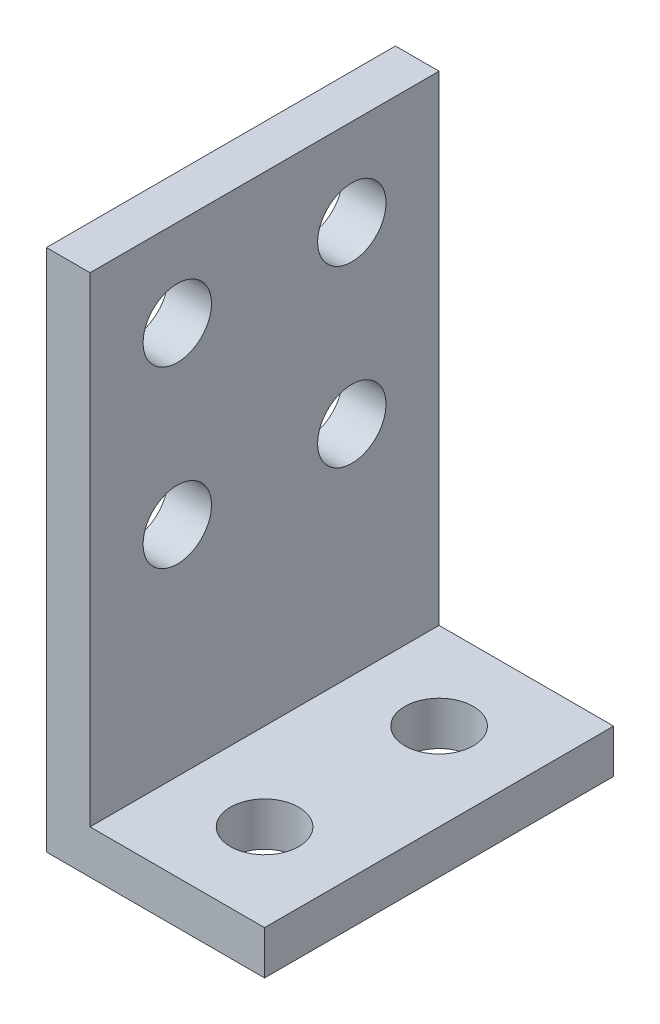
from build123d import *

# Parameters (mm, degrees)
BOSS_EXTRUDE1_DEPTH = 25.4
SKETCH2_R           = 2.4892
CUT_EXTRUDE1_DEPTH  = 4.175
SKETCH4_R           = 2.4892
CUT_EXTRUDE2_DEPTH  = 16.875


with BuildPart() as part:
    # Sketch1 → Boss-Extrude1 (new body)
    with BuildSketch(Plane.XY):
        Polygon((0, 0), (0, 38.1), (3.175, 38.1), (3.175, 3.175), (15.875, 3.175), (15.875, 0), align=None)
    extrude(amount=BOSS_EXTRUDE1_DEPTH)

    # Sketch2 → Cut-Extrude1 (cut, through all)
    with BuildSketch(Plane(origin=(0, 3.175, 0), x_dir=(1, 0, 0), z_dir=(0, 1, 0))):
        with Locations((9.525, -6.35)):
            Circle(SKETCH2_R)
        with Locations((9.525, -19.05)):
            Circle(SKETCH2_R)
    extrude(amount=-CUT_EXTRUDE1_DEPTH, mode=Mode.SUBTRACT)

    # Sketch4 → Cut-Extrude2 (cut, through all)
    with BuildSketch(Plane.ZY):
        with Locations((6.35, 31.75)):
            Circle(SKETCH4_R)
        with Locations((19.05, 31.75)):
            Circle(SKETCH4_R)
        with Locations((19.05, 19.05)):
            Circle(SKETCH4_R)
        with Locations((6.35, 19.05)):
            Circle(SKETCH4_R)
    extrude(amount=-CUT_EXTRUDE2_DEPTH, mode=Mode.SUBTRACT)


solid = part.part
